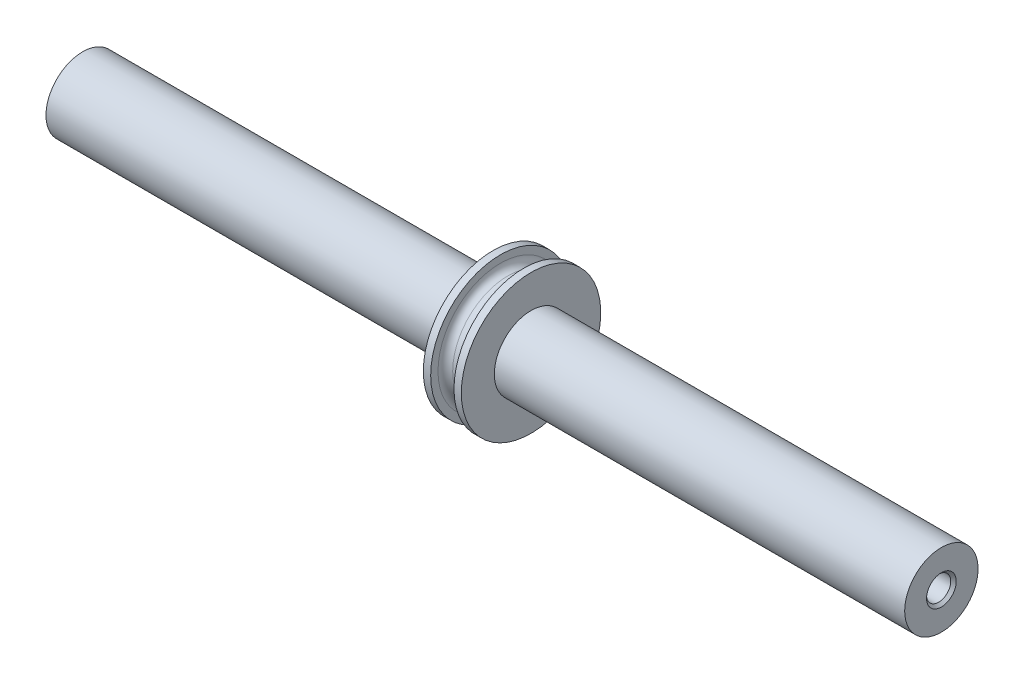
from build123d import *

# Parameters (mm, degrees)
SKETCH1_W   = 1.5875
SKETCH1_H   = 7.5
SKETCH1_W_2 = 1
SKETCH1_H_2 = 9.5
SKETCH1_W_3 = 55.9125
SKETCH1_H_3 = 5
FILLET1_R   = 1


with BuildPart() as part:
    # Sketch1 → Revolve1 (revolve)
    with BuildSketch(Plane(origin=(0, 0, 0), x_dir=(1, 0, 0), z_dir=(0, 1, 0))):
        Polygon((-2.5875, 0), (-1.5875, 0), (-1.5875, 7.5), (-1.5875, 9.5), (-2.5875, 9.5), (-2.5875, 5), align=None)
        with Locations((-0.79375, 3.75)):
            Rectangle(SKETCH1_W, SKETCH1_H)
        with Locations((0.79375, 3.75)):
            Rectangle(SKETCH1_W, SKETCH1_H)
        with Locations((2.0875, 4.75)):
            Rectangle(SKETCH1_W_2, SKETCH1_H_2)
        with Locations((-30.54375, 2.5)):
            Rectangle(SKETCH1_W_3, SKETCH1_H_3)
        with Locations((30.54375, 2.5)):
            Rectangle(SKETCH1_W_3, SKETCH1_H_3)
    revolve(axis=Axis((-2.646790194, 0, 0), (1, 0, 0)))

    # Fillet1
    fillet1_edges = [part.edges().sort_by_distance(p)[0] for p in [
        (-1.5875, 0, 7.5),
        (1.5875, 0, 7.5),
    ]]
    fillet(fillet1_edges, radius=FILLET1_R)

    # Sketch3 → M4x0.7 Tapped Hole1 (revolve, cut)
    with BuildSketch(Plane(origin=(-58.5, 0, 0), x_dir=(0, 0, 1), z_dir=(0, 1, 0))):
        Polygon((0, 0), (0, 15.991420021), (1.65, 15), (1.65, 0.375), (2.025, 0), align=None)
    m4x0_7_tapped_hole1 = revolve(axis=Axis((-64.85, 0, 0), (1, 0, 0)), mode=Mode.SUBTRACT)

    # Mirror1: M4x0.7 Tapped Hole1 across plane
    add(m4x0_7_tapped_hole1.mirror(Plane(origin=(0, 0, 0), x_dir=(0, 0, 1), z_dir=(1, 0, 0))), mode=Mode.SUBTRACT)


solid = part.part
